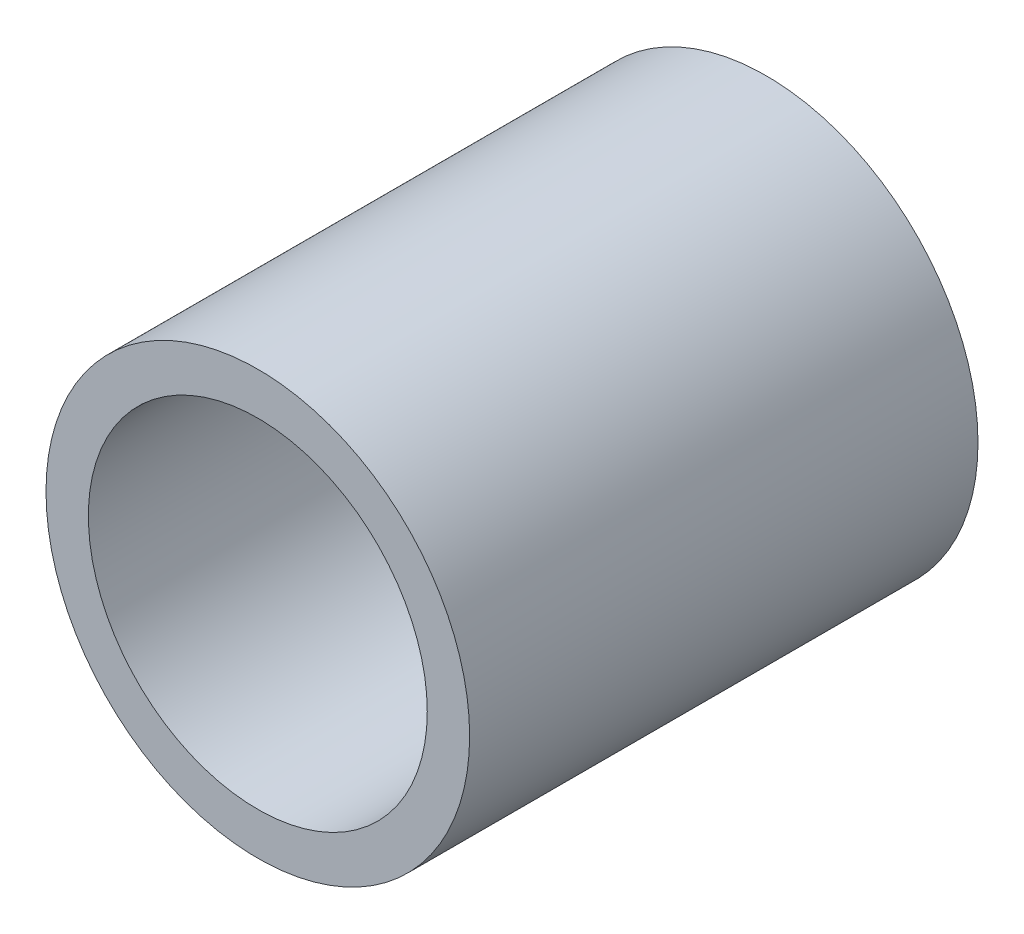
from build123d import *

# Parameters (mm, degrees)
SKETCH_1_R      = 2.5
EXTRUDE_1_DEPTH = 6
SHELL_1_T       = -0.5


with BuildPart() as part:
    # 草图1 → 凸台-拉伸1 (new body)
    with BuildSketch(Plane.XY):
        Circle(SKETCH_1_R)
    extrude(amount=EXTRUDE_1_DEPTH)

    # 抽壳1
    shell_1_openings = [part.faces().sort_by_distance(p)[0] for p in [
        (0, 0, 6),
    ]]
    offset(amount=SHELL_1_T, openings=shell_1_openings, kind=Kind.INTERSECTION)


solid = part.part
